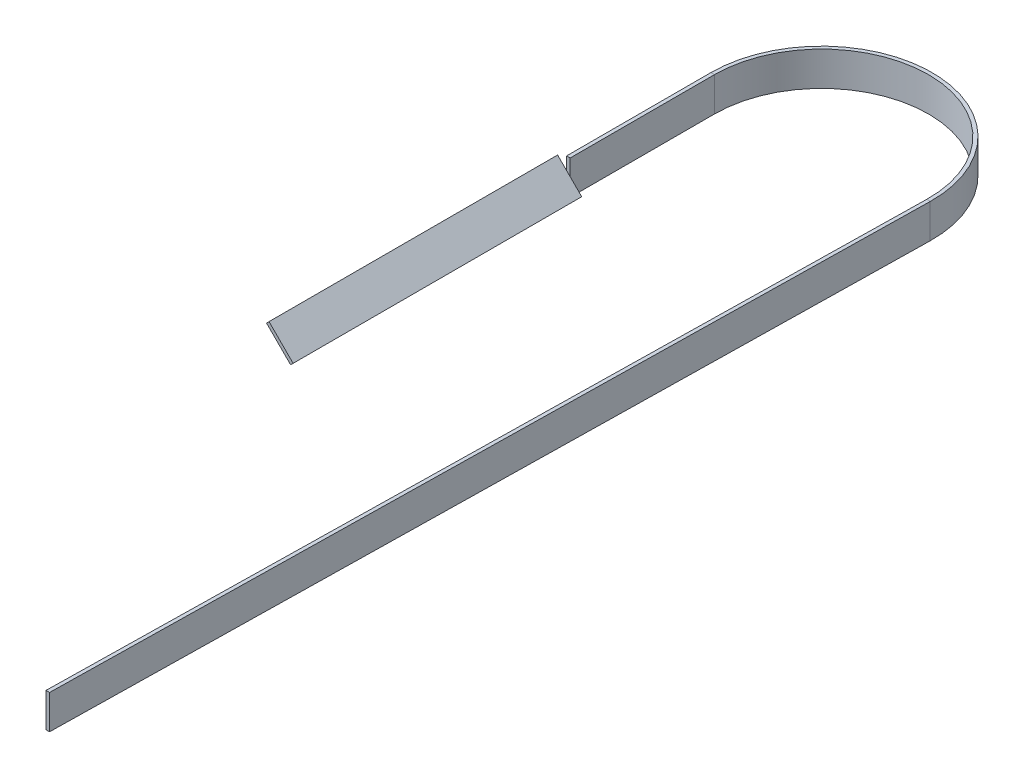
from build123d import *

# Parameters (mm, degrees)
SKETCH2_W           = 0.63000001
SKETCH2_H           = 6
BOSS_EXTRUDE1_DEPTH = 50.8


with BuildPart() as part:
    # Sweep1: sweep along a path in Sketch1
    with BuildLine(Plane(origin=(0, 0, 0), x_dir=(1, 0, 0), z_dir=(0, 1, 0))) as sweep1_path:
        Line((-18.8468, -25.4), (-18.8468, 0))
        ThreePointArc((-18.8468, 0), (0.164467269, 18.846082372), (18.843929541, -0.328922014))
        Line((18.843929541, -0.328922014), (16.1841828, -152.705710755))
    # Sketch2 → Sweep1 (sweep)
    with BuildSketch(Plane(origin=(-18.8468, 0, 25.4), x_dir=(-1, 0, 0), z_dir=(0, 0, -1))):
        with Locations((0.315000005, -3)):
            Rectangle(SKETCH2_W, SKETCH2_H)
    sweep(path=sweep1_path.line)

    # Sketch3 → Boss-Extrude1 (add)
    with BuildSketch(Plane.XY.offset(25.4)):
        Polygon((-21.060381709, -0.655941017), (-16.817741022, -4.898581704), (-17.263218301, -5.344058983), (-21.505858988, -1.101418296), align=None)
    extrude(amount=BOSS_EXTRUDE1_DEPTH)


solid = part.part
